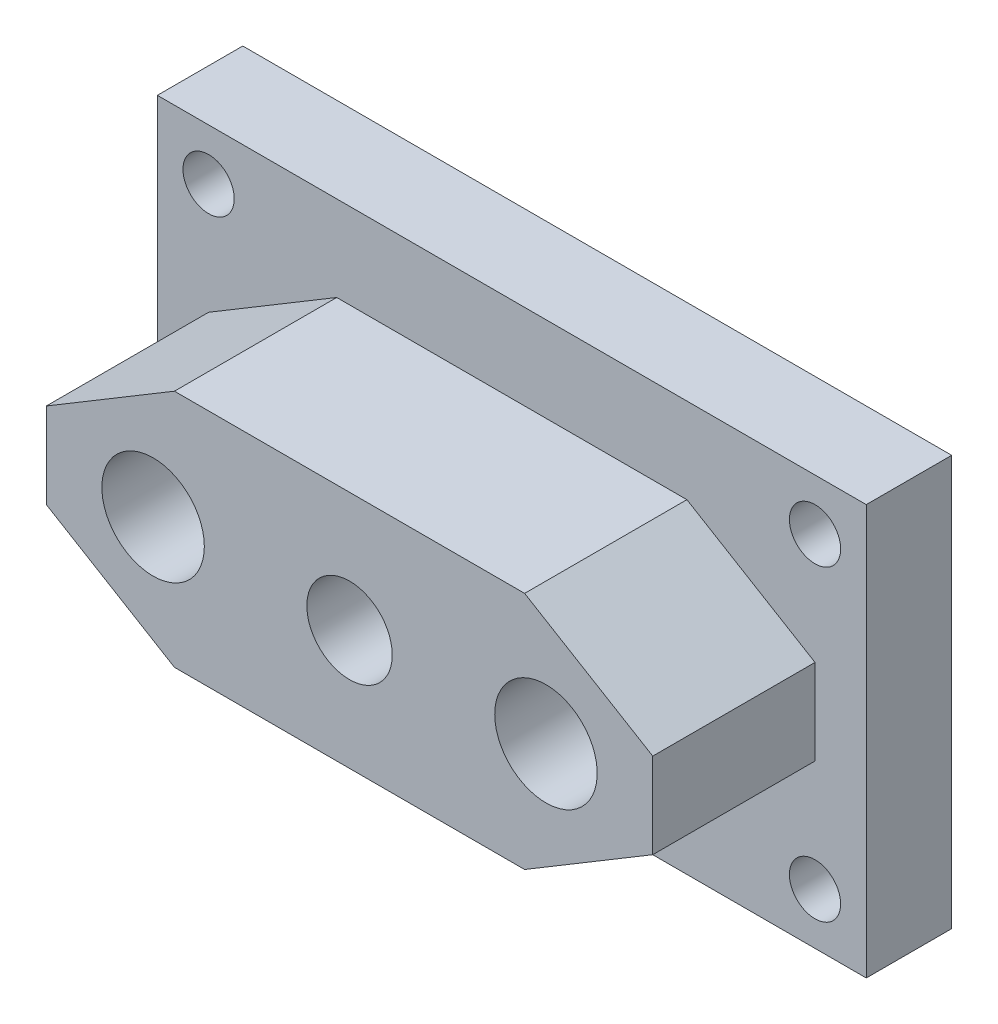
from build123d import *

# Parameters (mm, degrees)
SKETCH1_W           = 83
SKETCH1_H           = 48
BOSS_EXTRUDE1_DEPTH = 10
BOSS_EXTRUDE2_DEPTH = 19
SKETCH3_R           = 5
SKETCH3_R_2         = 6
SKETCH3_R_3         = 3
CUT_EXTRUDE1_DEPTH  = 30


with BuildPart() as part:
    # Sketch1 → Boss-Extrude1 (new body)
    with BuildSketch(Plane.XY):
        Rectangle(SKETCH1_W, SKETCH1_H)
    extrude(amount=BOSS_EXTRUDE1_DEPTH)

    # Sketch2 → Boss-Extrude2 (add)
    with BuildSketch(Plane.XY.offset(10)):
        Polygon((-35.5, 5), (-20.5, 14), (20.5, 14), (35.5, 5), (35.5, -5), (20.5, -14), (-20.5, -14), (-35.5, -5), align=None)
    extrude(amount=BOSS_EXTRUDE2_DEPTH)

    # Sketch3 → Cut-Extrude1 (cut, through all)
    with BuildSketch(Plane.XY.offset(29)):
        Circle(SKETCH3_R)
        with Locations((-23, 0)):
            Circle(SKETCH3_R_2)
        with Locations((23, 0)):
            Circle(SKETCH3_R_2)
        with Locations((-35.5, 18)):
            Circle(SKETCH3_R_3)
        with Locations((35.5, 18)):
            Circle(SKETCH3_R_3)
        with Locations((35.5, -18)):
            Circle(SKETCH3_R_3)
        with Locations((-35.5, -18)):
            Circle(SKETCH3_R_3)
    extrude(amount=-CUT_EXTRUDE1_DEPTH, mode=Mode.SUBTRACT)


solid = part.part
